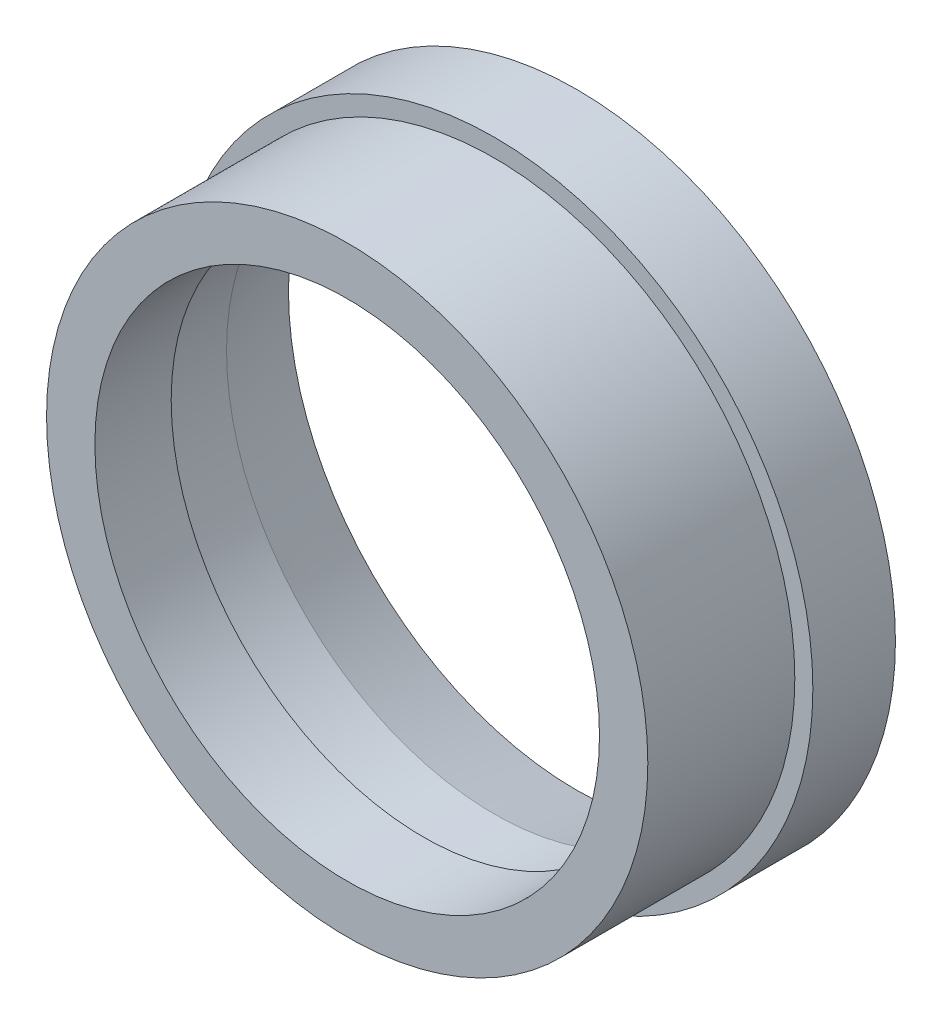
from build123d import *

# Parameters (mm, degrees)
SKETCH1_R         = 49
SKETCH1_R_2       = 38.7985
EXTRUDE1_DEPTH    = 35.306
SKETCH2_OUTSIDE_W = 128.604
SKETCH2_OUTSIDE_H = 128.604
SKETCH2_OUTSIDE_R = 46.228
EXTRUDE2_DEPTH    = 22.606
SKETCH3_R         = 41.1607
EXTRUDE3_DEPTH    = 23.5712
CHAMFER1_SIZE     = 3.175
CHAMFER1_SIZE2    = 12.7


with BuildPart() as part:
    # Sketch1 → Extrude1 (new body)
    with BuildSketch(Plane.XY):
        Circle(SKETCH1_R)
        Circle(SKETCH1_R_2, mode=Mode.SUBTRACT)
    extrude(amount=EXTRUDE1_DEPTH)

    # Sketch2 outside → Extrude2 (cut)
    with BuildSketch(Plane.XY.offset(35.306)):
        Rectangle(SKETCH2_OUTSIDE_W, SKETCH2_OUTSIDE_H)
        Circle(SKETCH2_OUTSIDE_R, mode=Mode.SUBTRACT)
    extrude(amount=-EXTRUDE2_DEPTH, mode=Mode.SUBTRACT)

    # Sketch3 → Extrude3 (cut)
    with BuildSketch(Plane(origin=(0, 0, 0), x_dir=(-1, 0, 0), z_dir=(0, 0, -1))):
        Circle(SKETCH3_R)
    extrude(amount=-EXTRUDE3_DEPTH, mode=Mode.SUBTRACT)

    # Chamfer1
    chamfer1_edges = [part.edges().sort_by_distance(p)[0] for p in [
        (41.1607, 0, 0),
    ]]
    chamfer1_side = [part.faces().sort_by_distance(p)[0] for p in [
        (-47.614070709, 0, 0),
    ]]
    chamfer(chamfer1_edges, length=CHAMFER1_SIZE, length2=CHAMFER1_SIZE2, reference=chamfer1_side[0])


solid = part.part
